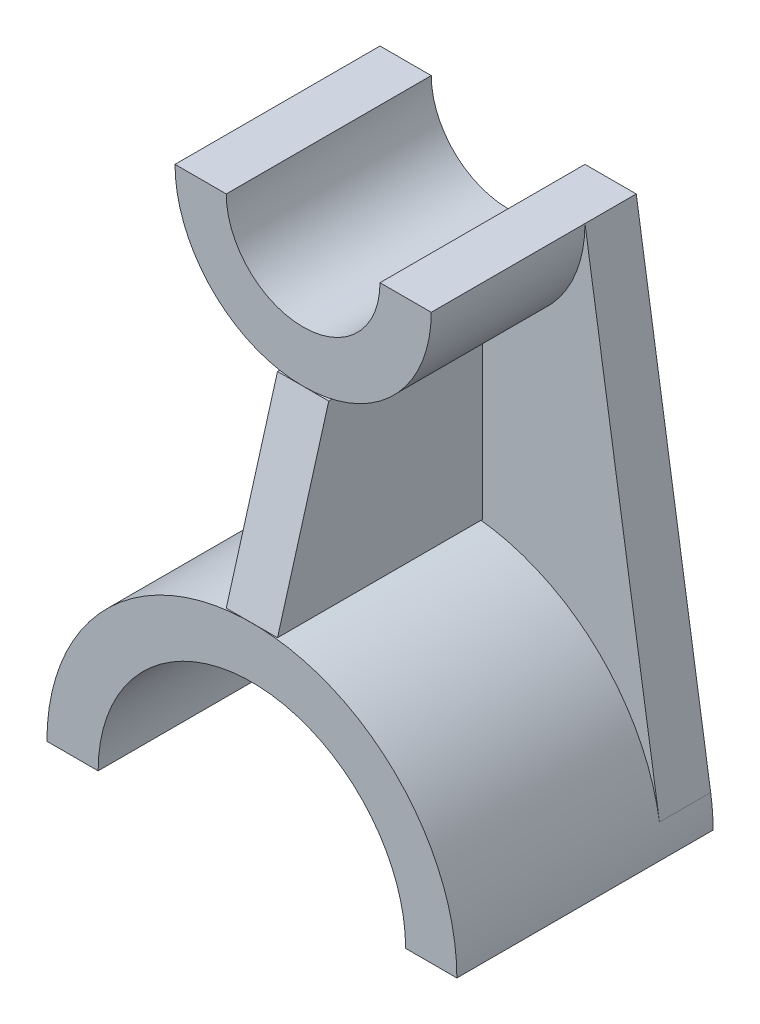
from build123d import *

# Parameters (mm, degrees)
BOSS_EXTRUDE1_DEPTH = 50
BOSS_EXTRUDE4_DEPTH = 40
BOSS_EXTRUDE6_DEPTH = 10
BOSS_EXTRUDE8_DEPTH = 5


with BuildPart() as part:
    # Sketch1 → Boss-Extrude1 (new body)
    with BuildSketch(Plane.XY):
        with BuildLine():
            Line((-40, 0), (-30, 0))
            ThreePointArc((-30, 0), (0, 30), (30, 0))
            Line((30, 0), (40, 0))
            ThreePointArc((40, 0), (0, 40), (-40, 0))
        make_face()
    extrude(amount=BOSS_EXTRUDE1_DEPTH)



with BuildPart() as body_2:
    # Sketch2 → Boss-Extrude4 (new body)
    with BuildSketch(Plane.XY):
        with BuildLine():
            Line((-25, 100), (-15, 100))
            ThreePointArc((-15, 100), (0, 85), (15, 100))
            Line((15, 100), (25, 100))
            ThreePointArc((25, 100), (0, 75), (-25, 100))
        make_face()
    extrude(amount=BOSS_EXTRUDE4_DEPTH)


with BuildPart() as part_1:
    add(part.part)

    add(body_2.part)  # Boss-Extrude6 merges body 2
    # Sketch6 → Boss-Extrude6 (add)
    with BuildSketch(Plane(origin=(0, 0, 0), x_dir=(-1, 0, 0), z_dir=(0, 0, -1))):
        with BuildLine():
            Line((-25, 100), (-39.529411765, 6.117647059))
            ThreePointArc((-39.529411765, 6.117647059), (0, 40), (39.529411765, 6.117647059))
            Line((39.529411765, 6.117647059), (25, 100))
            ThreePointArc((25, 100), (0, 75), (-25, 100))
        make_face()
    extrude(amount=-BOSS_EXTRUDE6_DEPTH)


with BuildPart() as body_2_2:
    # Sketch7 → Boss-Extrude8 (new body, symmetric)
    with BuildSketch(Plane(origin=(0, 0, 0), x_dir=(0, 0, -1), z_dir=(1, 0, 0))):
        Polygon((-40, 75), (-50, 40), (-10, 40), (-10, 75), align=None)
    extrude(amount=BOSS_EXTRUDE8_DEPTH, both=True)


solid = Compound([part_1.part, body_2_2.part])
